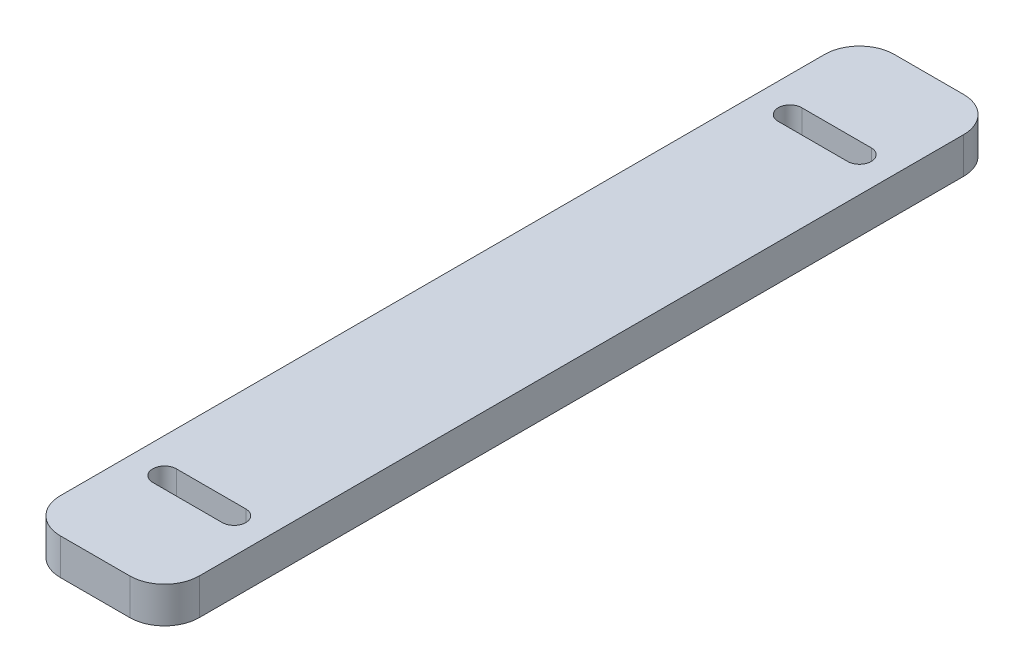
from build123d import *

# Parameters (mm, degrees)
SKETCH1_W           = 25.4
SKETCH1_H           = 152.4
BOSS_EXTRUDE1_DEPTH = 6.604
CUT_EXTRUDE1_DEPTH  = 7.604
FILLET1_R           = 6.35


with BuildPart() as part:
    # Sketch1 → Boss-Extrude1 (new body)
    with BuildSketch(Plane(origin=(0, 0, 0), x_dir=(1, 0, 0), z_dir=(0, 1, 0))):
        Rectangle(SKETCH1_W, SKETCH1_H)
    extrude(amount=BOSS_EXTRUDE1_DEPTH)

    # Sketch2 → Cut-Extrude1 (cut, through all)
    with BuildSketch(Plane(origin=(0, 6.604, 0), x_dir=(1, 0, 0), z_dir=(0, 1, 0))):
        with BuildLine():
            Line((-6.35, 59.309), (6.35, 59.309))
            ThreePointArc((6.35, 59.309), (8.509, 57.15), (6.35, 54.991))
            Line((6.35, 54.991), (-6.35, 54.991))
            ThreePointArc((-6.35, 54.991), (-8.509, 57.15), (-6.35, 59.309))
        make_face()
        with BuildLine():
            Line((-6.35, -54.991), (6.35, -54.991))
            ThreePointArc((6.35, -54.991), (8.509, -57.15), (6.35, -59.309))
            Line((6.35, -59.309), (-6.35, -59.309))
            ThreePointArc((-6.35, -59.309), (-8.509, -57.15), (-6.35, -54.991))
        make_face()
    extrude(amount=-CUT_EXTRUDE1_DEPTH, mode=Mode.SUBTRACT)

    # Fillet1
    fillet1_edges = [part.edges().sort_by_distance(p)[0] for p in [
        (-12.7, 3.302, -76.2),
        (12.7, 3.302, -76.2),
        (12.7, 3.302, 76.2),
        (-12.7, 3.302, 76.2),
    ]]
    fillet(fillet1_edges, radius=FILLET1_R)


solid = part.part
